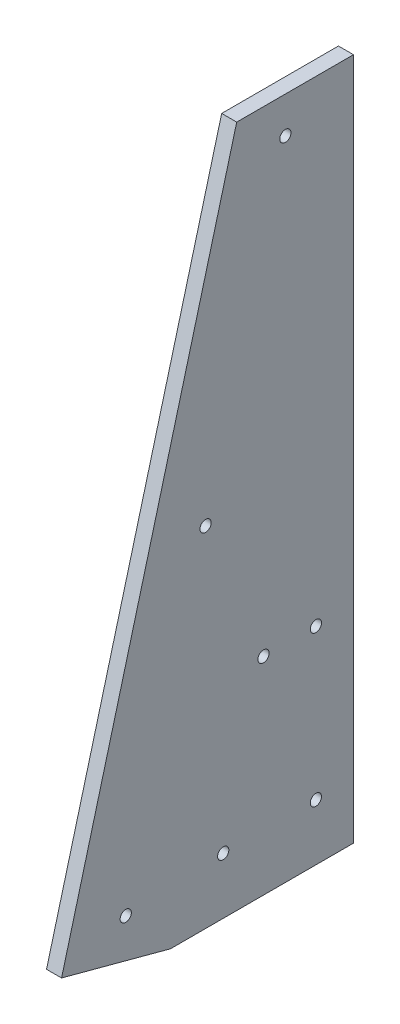
from build123d import *

# Parameters (mm, degrees)
BOSS_EXTRUDE1_DEPTH   = 5.08
F_6_CLEARANCE_HOLE1_D = 3.7973


with BuildPart() as part:
    # Sketch1 → Boss-Extrude1 (new body)
    with BuildSketch(Plane(origin=(0, 0, 0), x_dir=(0, 0, -1), z_dir=(1, 0, 0))):
        Polygon((0, 0), (-36.801773982, 9.861005618), (22.364259729, 230.671649508), (61.808282202, 230.671649508), (61.808282202, 0), align=None)
    extrude(amount=BOSS_EXTRUDE1_DEPTH)

    # #6 Clearance Hole1 (through all)
    with Locations(Plane(origin=(5.08, 0, 0), x_dir=(0, 0, -1), z_dir=(1, 0, 0))):
        with Locations((49.108282202, 69.85), (38.799269093, 218.404391514), (11.842691987, 117.801076159), (-15.113885118, 17.197760803), (49.108282202, 19.05), (17.804432116, 19.05), (31.416251091, 69.85)):
            Hole(F_6_CLEARANCE_HOLE1_D / 2)


solid = part.part
